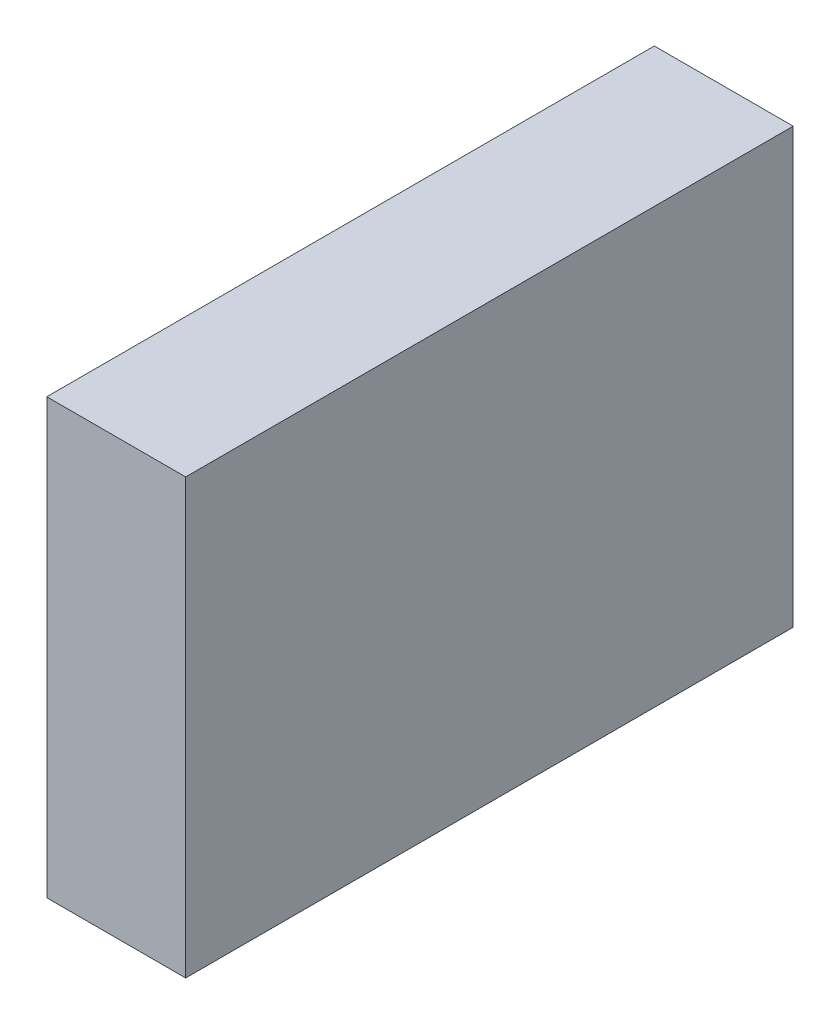
from build123d import *

# Parameters (mm, degrees)
SKETCH1_W           = 35
SKETCH1_H           = 25
BOSS_EXTRUDE1_DEPTH = 8


with BuildPart() as part:
    # Sketch1 → Boss-Extrude1 (new body)
    with BuildSketch(Plane(origin=(0, 0, 0), x_dir=(0, 0, -1), z_dir=(1, 0, 0))):
        Rectangle(SKETCH1_W, SKETCH1_H)
    extrude(amount=BOSS_EXTRUDE1_DEPTH)


solid = part.part
